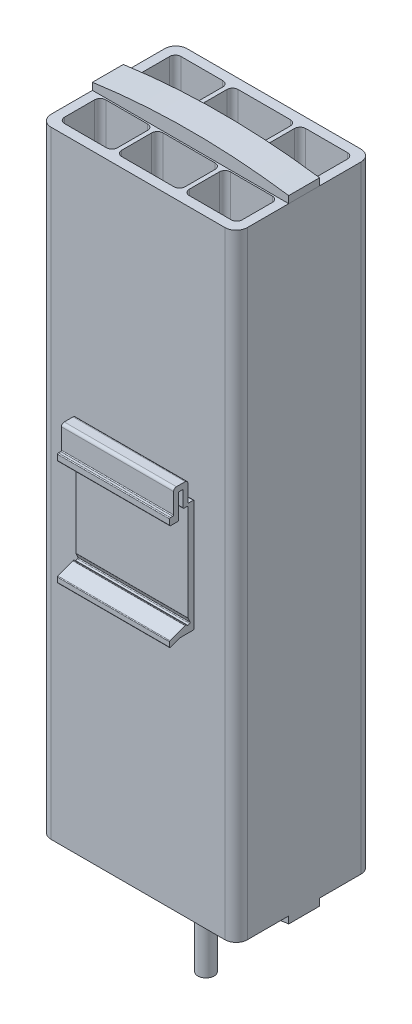
from build123d import *

# Parameters (mm, degrees)
SKETCH_1_W                  = 70
SKETCH_1_H                  = 220
EXTRUDE_1_DEPTH             = 48.5
CUT_EXTRUDE_1_REACH         = 222
SKETCH_2_W                  = 22.6
SKETCH_2_H                  = 14.7
SKETCH_2_W_2                = 18.9
SKETCH_3_W                  = 70
SKETCH_3_H                  = 11
EXTRUDE_2_DEPTH             = 5
CUT_EXTRUDE_4_DEPTH         = 11
EXTRUDE_3_REACH             = 26.25
EXTRUDE_3_DIRECTION_2_REACH = 26.25
EXTRUDE_6_DEPTH             = 20
FILLET_1_R                  = 4
FILLET_2_R                  = 2
SKETCH_13_OUTSIDE_W         = 123.742
SKETCH_13_OUTSIDE_H         = 111.042
SKETCH_13_OUTSIDE_R         = 5.5
CUT_EXTRUDE_8_DEPTH         = 3
SKETCH_14_R                 = 2.9
EXTRUDE_7_DEPTH             = 20


with BuildPart() as part:
    # Эскиз1 → Бобышка-Вытянуть1 (new body)
    with BuildSketch(Plane.XY):
        Rectangle(SKETCH_1_W, SKETCH_1_H)
    extrude(amount=EXTRUDE_1_DEPTH)

    # Эскиз2 → Вырез-Вытянуть1 (cut, up to next)
    with BuildSketch(Plane(origin=(0, 110, 0), x_dir=(1, 0, 0), z_dir=(0, 1, 0)), mode=Mode.PRIVATE) as cut_extrude_1_sk1:
        with Locations((0, -10.85)):
            Rectangle(SKETCH_2_W, SKETCH_2_H)
    cut_extrude_1_tool1 = extrude(cut_extrude_1_sk1.sketch, amount=-CUT_EXTRUDE_1_REACH, mode=Mode.PRIVATE) & part.part
    add(cut_extrude_1_tool1.solids().sort_by_distance((0, 110, 10.85))[0], mode=Mode.SUBTRACT)
    # Эскиз2 → Вырез-Вытянуть1 (cut, up to next)
    with BuildSketch(Plane(origin=(0, 110, 0), x_dir=(1, 0, 0), z_dir=(0, 1, 0)), mode=Mode.PRIVATE) as cut_extrude_1_sk2:
        with Locations((22.25, -10.85)):
            Rectangle(SKETCH_2_W_2, SKETCH_2_H)
    cut_extrude_1_tool2 = extrude(cut_extrude_1_sk2.sketch, amount=-CUT_EXTRUDE_1_REACH, mode=Mode.PRIVATE) & part.part
    add(cut_extrude_1_tool2.solids().sort_by_distance((22.25, 110, 10.85))[0], mode=Mode.SUBTRACT)
    # Эскиз2 → Вырез-Вытянуть1 (cut, up to next)
    with BuildSketch(Plane(origin=(0, 110, 0), x_dir=(1, 0, 0), z_dir=(0, 1, 0)), mode=Mode.PRIVATE) as cut_extrude_1_sk3:
        with Locations((-22.25, -10.85)):
            Rectangle(SKETCH_2_W_2, SKETCH_2_H)
    cut_extrude_1_tool3 = extrude(cut_extrude_1_sk3.sketch, amount=-CUT_EXTRUDE_1_REACH, mode=Mode.PRIVATE) & part.part
    add(cut_extrude_1_tool3.solids().sort_by_distance((-22.25, 110, 10.85))[0], mode=Mode.SUBTRACT)
    # Эскиз2 → Вырез-Вытянуть1 (cut, up to next)
    with BuildSketch(Plane(origin=(0, 110, 0), x_dir=(1, 0, 0), z_dir=(0, 1, 0)), mode=Mode.PRIVATE) as cut_extrude_1_sk4:
        with Locations((22.25, -37.65)):
            Rectangle(SKETCH_2_W_2, SKETCH_2_H)
    cut_extrude_1_tool4 = extrude(cut_extrude_1_sk4.sketch, amount=-CUT_EXTRUDE_1_REACH, mode=Mode.PRIVATE) & part.part
    add(cut_extrude_1_tool4.solids().sort_by_distance((22.25, 110, 37.65))[0], mode=Mode.SUBTRACT)
    # Эскиз2 → Вырез-Вытянуть1 (cut, up to next)
    with BuildSketch(Plane(origin=(0, 110, 0), x_dir=(1, 0, 0), z_dir=(0, 1, 0)), mode=Mode.PRIVATE) as cut_extrude_1_sk5:
        with Locations((0, -37.65)):
            Rectangle(SKETCH_2_W, SKETCH_2_H)
    cut_extrude_1_tool5 = extrude(cut_extrude_1_sk5.sketch, amount=-CUT_EXTRUDE_1_REACH, mode=Mode.PRIVATE) & part.part
    add(cut_extrude_1_tool5.solids().sort_by_distance((0, 110, 37.65))[0], mode=Mode.SUBTRACT)
    # Эскиз2 → Вырез-Вытянуть1 (cut, up to next)
    with BuildSketch(Plane(origin=(0, 110, 0), x_dir=(1, 0, 0), z_dir=(0, 1, 0)), mode=Mode.PRIVATE) as cut_extrude_1_sk6:
        with Locations((-22.25, -37.65)):
            Rectangle(SKETCH_2_W_2, SKETCH_2_H)
    cut_extrude_1_tool6 = extrude(cut_extrude_1_sk6.sketch, amount=-CUT_EXTRUDE_1_REACH, mode=Mode.PRIVATE) & part.part
    add(cut_extrude_1_tool6.solids().sort_by_distance((-22.25, 110, 37.65))[0], mode=Mode.SUBTRACT)


with BuildPart() as body_2:
    # Эскиз3 → Бобышка-Вытянуть2 (new body)
    with BuildSketch(Plane(origin=(0, 110, 0), x_dir=(1, 0, 0), z_dir=(0, 1, 0))):
        with Locations((0, -24.25)):
            Rectangle(SKETCH_3_W, SKETCH_3_H)
    extrude_2 = extrude(amount=EXTRUDE_2_DEPTH)

    # Эскиз4 → Вырез-Вытянуть4 (cut)
    with BuildSketch(Plane.XY.offset(29.75)):
        with BuildLine():
            Line((-35, 112.5), (-35, 118.5))
            Line((-35, 118.5), (35, 118.5))
            Line((35, 118.5), (35, 112.5))
            ThreePointArc((35, 112.5), (0, 115), (-35, 112.5))
        make_face()
    cut_extrude_4 = extrude(amount=-CUT_EXTRUDE_4_DEPTH, mode=Mode.SUBTRACT)


with BuildPart() as part_1:
    add(part.part)

    # Зеркальное отражение2: Бобышка-Вытянуть2, Вырез-Вытянуть4 across plane
    add(extrude_2.mirror(Plane.ZX))
    add(cut_extrude_4.mirror(Plane.ZX), mode=Mode.SUBTRACT)

    # Бобышка-Вытянуть3: up to this face of the body (flat: up to its plane)
    extrude_3_end = Plane(part_1.part.faces().sort_by_distance((0, -112.150725053, 18.75))[0])
    # Эскиз5 → Бобышка-Вытянуть3 (add, up to the picked face)
    with BuildSketch(Plane(origin=(0, 0, 24.25), x_dir=(-1, 0, 0), z_dir=(0, 0, -1)), mode=Mode.PRIVATE) as extrude_3_sk1:
        with BuildLine():
            Line((-11.5, -124.377385485), (-17.5, -114.377385485))
            ThreePointArc((-17.5, -114.377385485), (0, -115), (17.5, -114.377385485))
            Line((17.5, -114.377385485), (11.5, -124.377385485))
            Line((11.5, -124.377385485), (6.15, -124.377385485))
            Line((6.15, -124.377385485), (6.15, -127.377385485))
            Line((6.15, -127.377385485), (-6.15, -127.377385485))
            Line((-6.15, -127.377385485), (-6.15, -124.377385485))
            Line((-6.15, -124.377385485), (-11.5, -124.377385485))
        make_face()
    extrude_3_tool1 = split(extrude(extrude_3_sk1.sketch, amount=EXTRUDE_3_REACH, mode=Mode.PRIVATE), bisect_by=extrude_3_end, keep=Keep.BOTH, mode=Mode.PRIVATE)
    add(extrude_3_tool1.solids().sort_by(Axis((0, -120.046106, 24.25), (0, 0, -1)))[0])

    # Бобышка-Вытянуть3 direction 2: up to this face of the body (flat: up to its plane)
    extrude_3_direction_2_end = Plane(part_1.part.faces().sort_by_distance((0, -112.150725053, 29.75))[0])
    # Эскиз5 → Бобышка-Вытянуть3 direction 2 (add, up to the picked face)
    with BuildSketch(Plane(origin=(0, 0, 24.25), x_dir=(-1, 0, 0), z_dir=(0, 0, -1)), mode=Mode.PRIVATE) as extrude_3_direction_2_sk1:
        with BuildLine():
            Line((-11.5, -124.377385485), (-17.5, -114.377385485))
            ThreePointArc((-17.5, -114.377385485), (0, -115), (17.5, -114.377385485))
            Line((17.5, -114.377385485), (11.5, -124.377385485))
            Line((11.5, -124.377385485), (6.15, -124.377385485))
            Line((6.15, -124.377385485), (6.15, -127.377385485))
            Line((6.15, -127.377385485), (-6.15, -127.377385485))
            Line((-6.15, -127.377385485), (-6.15, -124.377385485))
            Line((-6.15, -124.377385485), (-11.5, -124.377385485))
        make_face()
    extrude_3_direction_2_tool1 = split(extrude(extrude_3_direction_2_sk1.sketch, amount=-EXTRUDE_3_DIRECTION_2_REACH, mode=Mode.PRIVATE), bisect_by=extrude_3_direction_2_end, keep=Keep.BOTH, mode=Mode.PRIVATE)
    add(extrude_3_direction_2_tool1.solids().sort_by(Axis((0, -120.046106, 24.25), (0, 0, 1)))[0])

    # Эскиз11 → Бобышка-Вытянуть6 (add, symmetric)
    with BuildSketch(Plane.ZY):
        with BuildLine():
            Line((48.8, -19.7), (53.446494712, -19.7))
            ThreePointArc((53.446494712, -19.7), (53.499168801, -19.704660466), (53.550206319, -19.718497065))
            Line((53.550206319, -19.718497065), (56.896288392, -20.951264145))
            ThreePointArc((56.896288392, -20.951264145), (57.171590381, -20.915844003), (57.3, -20.66976121))
            Line((57.3, -20.66976121), (57.3, -19.071198836))
            ThreePointArc((57.3, -19.071198836), (57.246082793, -18.899608455), (57.103711608, -18.789695901))
            Line((57.103711608, -18.789695901), (51.753314767, -16.818497065))
            ThreePointArc((51.753314767, -16.818497065), (51.702277249, -16.804660466), (51.649603159, -16.8))
            Line((51.649603159, -16.8), (51.395615132, -16.8))
            ThreePointArc((51.395615132, -16.8), (51.233596615, -16.847512377), (51.122897329, -16.975))
            Line((51.122897329, -16.975), (51.053098899, -17.127282197))
            ThreePointArc((51.053098899, -17.127282197), (50.884833356, -17.283511153), (50.655381096, -17.275))
            Line((50.655381096, -17.275), (50.10994549, -17.025))
            ThreePointArc((50.10994549, -17.025), (49.953716535, -16.856734457), (49.962227687, -16.627282197))
            Line((49.962227687, -16.627282197), (50.672717803, -15.077175771))
            ThreePointArc((50.672717803, -15.077175771), (50.693100103, -15.016147089), (50.7, -14.952175771))
            Line((50.7, -14.952175771), (50.7, 19.3))
            ThreePointArc((50.7, 19.3), (50.787867966, 19.512132034), (51, 19.6))
            Line((51, 19.6), (52.1, 19.6))
            ThreePointArc((52.1, 19.6), (52.312132034, 19.687867966), (52.4, 19.9))
            Line((52.4, 19.9), (52.4, 25.3))
            ThreePointArc((52.4, 25.3), (52.487867966, 25.512132034), (52.7, 25.6))
            Line((52.7, 25.6), (53.8, 25.6))
            ThreePointArc((53.8, 25.6), (54.012132034, 25.512132034), (54.1, 25.3))
            Line((54.1, 25.3), (54.1, 16.9))
            ThreePointArc((54.1, 16.9), (54.187867966, 16.687867966), (54.4, 16.6))
            Line((54.4, 16.6), (56.9, 16.6))
            ThreePointArc((56.9, 16.6), (57.112132034, 16.687867966), (57.2, 16.9))
            Line((57.2, 16.9), (57.2, 18.8))
            ThreePointArc((57.2, 18.8), (57.112132034, 19.012132034), (56.9, 19.1))
            Line((56.9, 19.1), (56.1, 19.1))
            ThreePointArc((56.1, 19.1), (55.887867966, 19.187867966), (55.8, 19.4))
            Line((55.8, 19.4), (55.8, 26.6))
            ThreePointArc((55.8, 26.6), (55.507106781, 27.307106781), (54.8, 27.6))
            Line((54.8, 27.6), (51.7, 27.6))
            ThreePointArc((51.7, 27.6), (50.992893219, 27.307106781), (50.7, 26.6))
            Line((50.7, 26.6), (50.7, 20.7))
            ThreePointArc((50.7, 20.7), (50.612132034, 20.487867966), (50.4, 20.4))
            Line((50.4, 20.4), (48.8, 20.4))
            ThreePointArc((48.8, 20.4), (48.587867966, 20.312132034), (48.5, 20.1))
            Line((48.5, 20.1), (48.5, -19.4))
            ThreePointArc((48.5, -19.4), (48.587867966, -19.612132034), (48.8, -19.7))
        make_face()
    extrude(amount=EXTRUDE_6_DEPTH, both=True)

    # Скругление1
    fillet_1_edges = [part_1.edges().sort_by_distance(p)[0] for p in [
        (-35, 0, 48.5),
        (35, 0, 48.5),
        (-35, 0, 0),
        (35, 0, 0),
    ]]
    fillet(fillet_1_edges, radius=FILLET_1_R)

    # Скругление2
    fillet_2_edges = [part_1.edges().sort_by_distance(p)[0] for p in [
        (31.7, 0, 3.5),
        (31.7, 0, 18.2),
        (12.8, 0, 18.2),
        (12.8, 0, 3.5),
        (-12.8, 0, 3.5),
        (-12.8, 0, 18.2),
        (-31.7, 0, 18.2),
        (-31.7, 0, 3.5),
        (12.8, 0, 45),
        (12.8, 0, 30.3),
        (31.7, 0, 30.3),
        (31.7, 0, 45),
        (-11.3, 0, 45),
        (-11.3, 0, 30.3),
        (11.3, 0, 30.3),
        (11.3, 0, 45),
        (-31.7, 0, 45),
        (-31.7, 0, 30.3),
        (-12.8, 0, 30.3),
        (-12.8, 0, 45),
        (11.3, 0, 3.5),
        (11.3, 0, 18.2),
        (-11.3, 0, 18.2),
        (-11.3, 0, 3.5),
    ]]
    fillet(fillet_2_edges, radius=FILLET_2_R)

    # Эскиз13 outside → Вырез-Вытянуть8 (cut)
    with BuildSketch(Plane.XZ.offset(127.377385485)):
        with Locations((0, 28.65)):
            Rectangle(SKETCH_13_OUTSIDE_W, SKETCH_13_OUTSIDE_H)
        with Locations(Location((0, 24.25, 0), (0, 0, 270))):  # turned: the seam where the file's is
            Circle(SKETCH_13_OUTSIDE_R, mode=Mode.SUBTRACT)
    extrude(amount=-CUT_EXTRUDE_8_DEPTH, mode=Mode.SUBTRACT)

    # Эскиз14 → Бобышка-Вытянуть7 (add)
    with BuildSketch(Plane.XZ.offset(127.377385485)):
        with Locations(Location((0, 24.25, 0), (0, 0, 270))):  # turned: the seam where the file's is
            Circle(SKETCH_14_R)
    extrude(amount=EXTRUDE_7_DEPTH)


solid = Compound([body_2.part, part_1.part])
